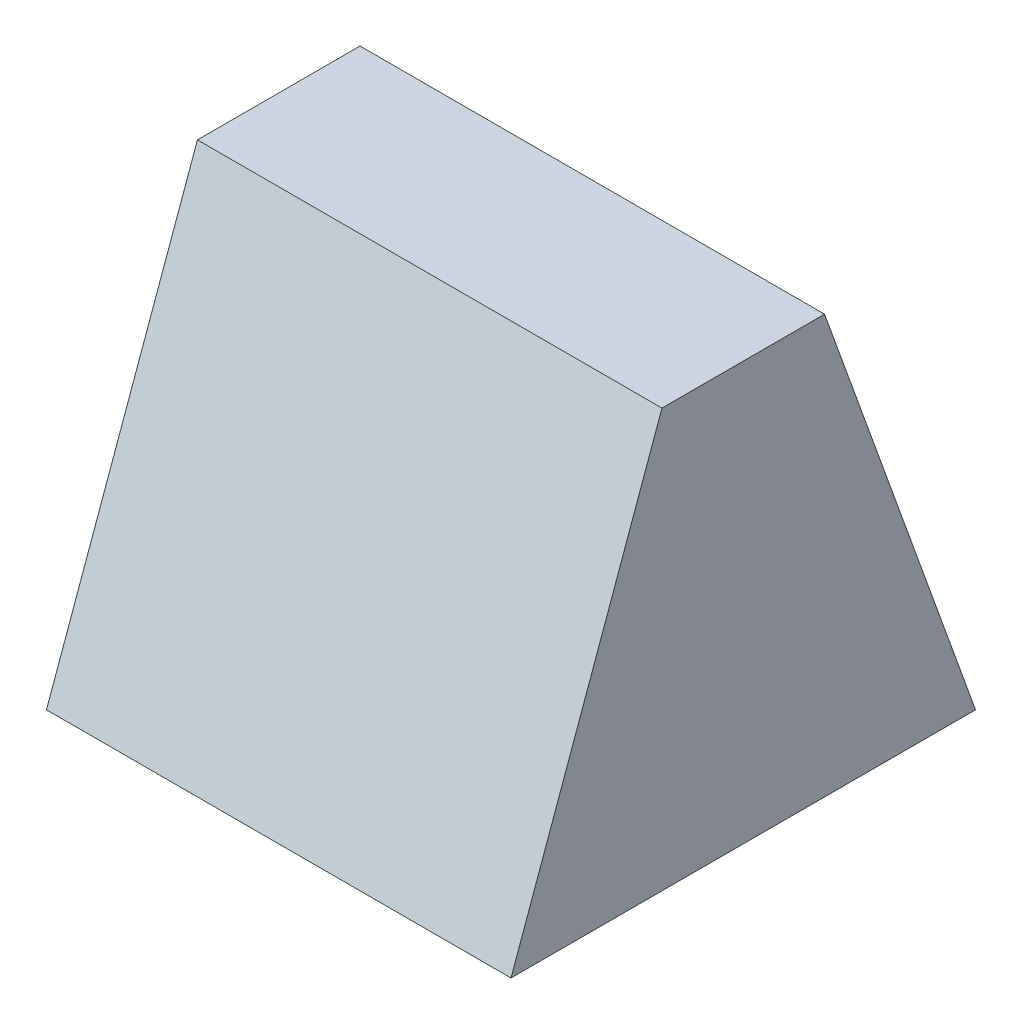
from build123d import *

# Parameters (mm, degrees)
ESTRUSIONE_ESTRUSIONE1_DEPTH = 10


with BuildPart() as part:
    # Schizzo1 → Estrusione-Estrusione1 (new body)
    with BuildSketch(Plane(origin=(0, -56.336339876, -180.947255955), x_dir=(0, 0, 1), z_dir=(-1, 0, 0))):
        Polygon((5, 13.410432688), (-5, 13.410432688), (-1.75, 22.410432688), (1.75, 22.410432688), align=None)
    extrude(amount=ESTRUSIONE_ESTRUSIONE1_DEPTH)


solid = part.part
